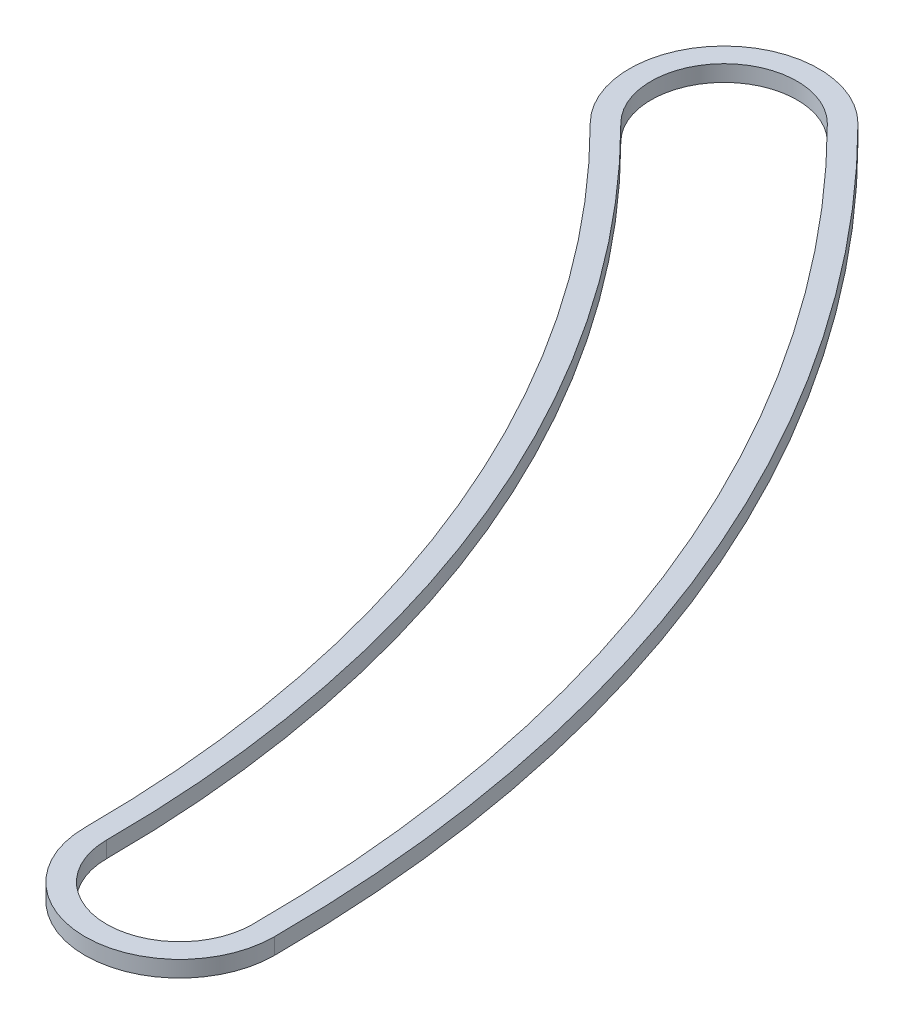
from build123d import *

# Parameters (mm, degrees)
BOSS_EXTRUDE1_DEPTH = 0.762


with BuildPart() as part:
    # Sketch1 → Boss-Extrude1 (new body)
    with BuildSketch(Plane(origin=(0, 0, 0), x_dir=(1, 0, 0), z_dir=(0, 1, 0))):
        with BuildLine():
            ThreePointArc((66.167, 0), (61.130337028, 25.321014669), (46.787134391, 46.787134391))
            ThreePointArc((46.787134391, 46.787134391), (40.500955106, 46.787134391), (40.500955106, 40.500955106))
            ThreePointArc((40.500955106, 40.500955106), (52.917047984, 21.918958956), (57.277, 0))
            ThreePointArc((57.277, 0), (61.722, -4.445), (66.167, 0))
        make_face()
        with BuildLine():
            ThreePointArc((65.151, 0), (60.191675423, 24.932208302), (46.068713901, 46.068713901))
            ThreePointArc((46.068713901, 46.068713901), (41.219375596, 46.068713901), (41.219375596, 41.219375596))
            ThreePointArc((41.219375596, 41.219375596), (53.855709589, 22.307765323), (58.293, 0))
            ThreePointArc((58.293, 0), (61.722, -3.429), (65.151, 0))
        make_face(mode=Mode.SUBTRACT)
    extrude(amount=BOSS_EXTRUDE1_DEPTH)


solid = part.part
